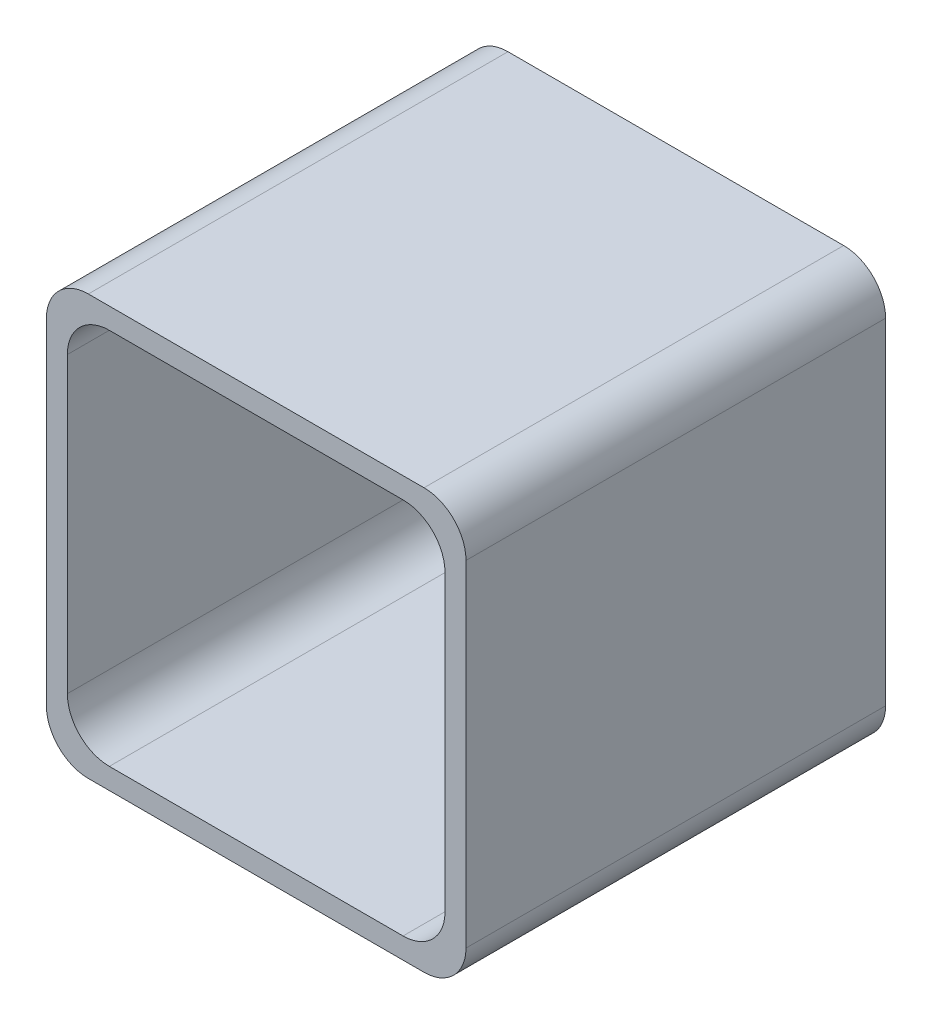
from build123d import *

# Parameters (mm, degrees)
SKETCH1_W                       = 50
SKETCH1_H                       = 50
BOSS_EXTRUDE1_DEPTH             = 50
SKETCH3_W                       = 45
SKETCH3_H                       = 45
CUT_EXTRUDE4_DEPTH              = 45
SKETCH5_R                       = 3
BOSS_EXTRUDE2_DEPTH             = 8
TAP_DRILL_FOR_M3X0_5_TAP2_D     = 2.5
TAP_DRILL_FOR_M3X0_5_TAP2_DEPTH = 8
TAP_DRILL_FOR_M3X0_5_TAP2_TIP   = 0.751075774
SKETCH10_R                      = 6
CUT_EXTRUDE5_DEPTH              = 5
FILLET2_R                       = 5


with BuildPart() as part:
    # Sketch1 → Boss-Extrude1 (new body)
    with BuildSketch(Plane.XY):
        Rectangle(SKETCH1_W, SKETCH1_H)
    extrude(amount=-BOSS_EXTRUDE1_DEPTH)

    # Sketch3 → Cut-Extrude4 (cut)
    with BuildSketch(Plane.XY):
        Rectangle(SKETCH3_W, SKETCH3_H)
    extrude(amount=-CUT_EXTRUDE4_DEPTH, mode=Mode.SUBTRACT)

    # Sketch5 → Boss-Extrude2 (add)
    with BuildSketch(Plane.XY.offset(-45)):
        with Locations((-14.5, 0)):
            Circle(SKETCH5_R)
        with Locations((14.5, 0)):
            Circle(SKETCH5_R)
    extrude(amount=BOSS_EXTRUDE2_DEPTH)

    # Tap Drill for M3x0.5 Tap2
    with Locations(Plane.XY.offset(-37)):
        with Locations((-14.5, 0), (14.5, 0)):
            Hole(TAP_DRILL_FOR_M3X0_5_TAP2_D / 2, depth=TAP_DRILL_FOR_M3X0_5_TAP2_DEPTH)
            with Locations((0, 0, -(TAP_DRILL_FOR_M3X0_5_TAP2_DEPTH + TAP_DRILL_FOR_M3X0_5_TAP2_TIP / 2))):  # 118° drill point
                Cone(0, TAP_DRILL_FOR_M3X0_5_TAP2_D / 2, TAP_DRILL_FOR_M3X0_5_TAP2_TIP, mode=Mode.SUBTRACT)

    # Sketch10 → Cut-Extrude5 (cut)
    with BuildSketch(Plane(origin=(0, -22.5, 0), x_dir=(1, 0, 0), z_dir=(0, 1, 0))):
        with Locations((0, 38.184638056)):
            Circle(SKETCH10_R)
    extrude(amount=-CUT_EXTRUDE5_DEPTH, mode=Mode.SUBTRACT)

    # Fillet2
    fillet2_edges = [part.edges().sort_by_distance(p)[0] for p in [
        (22.5, 22.5, -22.5),
        (22.5, -22.5, -22.5),
        (-22.5, -22.5, -22.5),
        (-22.5, 22.5, -22.5),
        (25, -25, -25),
        (-25, -25, -25),
        (-25, 25, -25),
        (25, 25, -25),
    ]]
    fillet(fillet2_edges, radius=FILLET2_R)


solid = part.part
